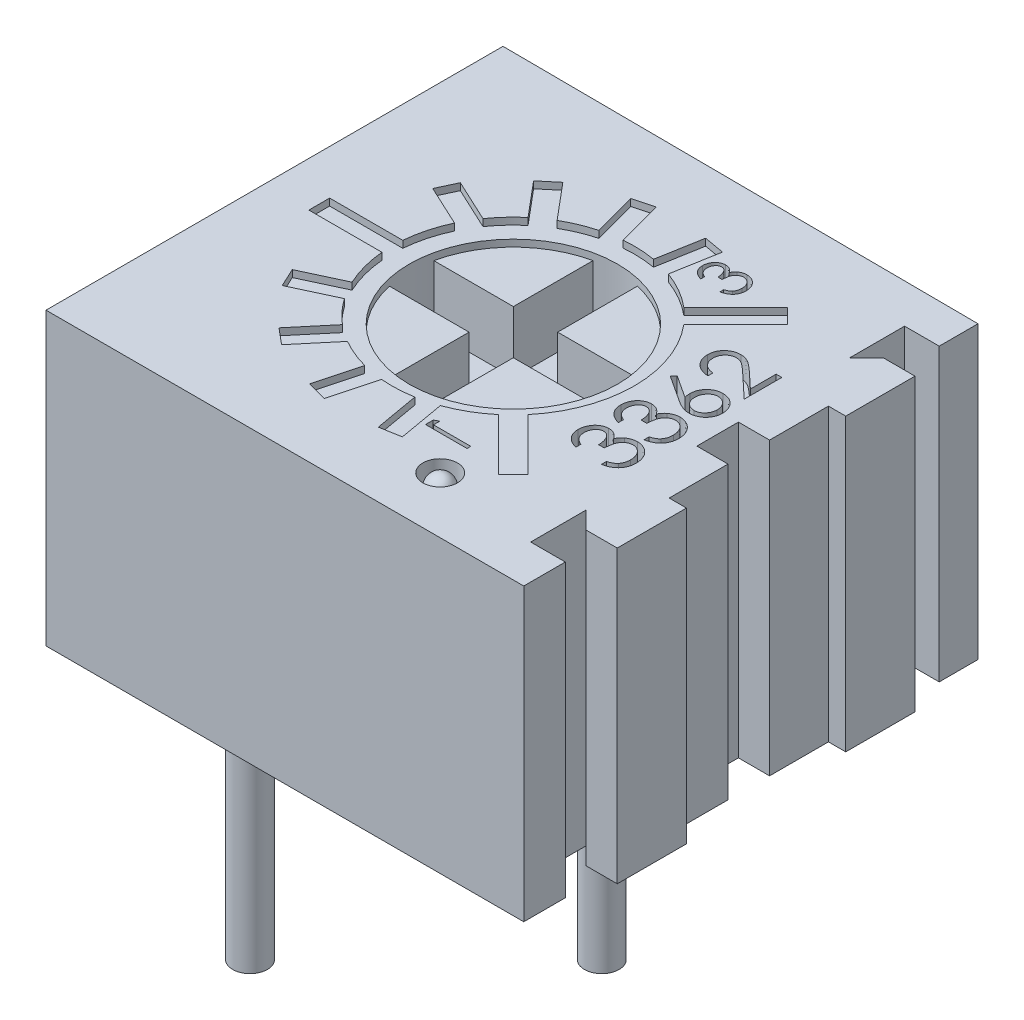
from build123d import *

# Parameters (mm, degrees)
BOSS_EXTRUDE1_DEPTH = 4.2
CUT_EXTRUDE3_DEPTH  = 0.2
CUT_EXTRUDE4_DEPTH  = 0.1
CUT_EXTRUDE5_DEPTH  = 0.5
CUT_EXTRUDE6_DEPTH  = 0.3
CUT_EXTRUDE7_DEPTH  = 0.89
SKETCH14_R          = 0.18
BOSS_EXTRUDE2_DEPTH = 0.32
REVOLVE1_ANGLE      = 180
BOSS_EXTRUDE3_DEPTH = 3.24


with BuildPart() as part:
    # Sketch3 → Boss-Extrude1 (new body)
    with BuildSketch(Plane(origin=(0, 0, 0), x_dir=(1, 0, 0), z_dir=(0, 1, 0))):
        Polygon((3.1, -1.938039121), (3.55, -1.938039121), (3.55, -0.938039121), (3.3, -0.938039121), (3.3, -0.088039121), (2.85, -0.088039121), (2.85, 0.511960879), (3.3, 0.511960879), (3.3, 1.361960879), (3.55, 1.361960879), (3.55, 2.361960879), (3.1, 2.361960879), (2.85, 2.111960879), (2.85, 2.911960879), (3.35, 2.911960879), (3.35, 3.472174064), (-3.55, 3.511960879), (-3.55, -3.088039121), (3.35, -3.088039121), (3.35, -2.488039121), (2.85, -2.488039121), (2.85, -1.688039121), align=None)
    extrude(amount=BOSS_EXTRUDE1_DEPTH)

    # Sketch5 → Cut-Extrude3 (cut)
    with BuildSketch(Plane(origin=(0, 4.2, 0), x_dir=(1, 0, 0), z_dir=(0, 1, 0))):
        with BuildLine():
            ThreePointArc((-1.60378018, 0.211962343), (-0.1, -1.291817837), (1.40378018, 0.211962343))
            ThreePointArc((1.40378018, 0.211962343), (-0.1, 1.715742524), (-1.60378018, 0.211962343))
        make_face()
    extrude(amount=-CUT_EXTRUDE3_DEPTH, mode=Mode.SUBTRACT)

    # Sketch5_5 → Cut-Extrude4 (cut)
    with BuildSketch(Plane(origin=(0, 4.2, 0), x_dir=(1, 0, 0), z_dir=(0, 1, 0))):
        with BuildLine():
            Line((-0.435140366, -2.183914718), (-0.260203012, -1.531039623))
            ThreePointArc((-0.260203012, -1.531039623), (-0.029388376, -1.536466305), (0.200131905, -1.511460589))
            Line((0.200131905, -1.511460589), (0.31300322, -2.151585629))
            Line((0.31300322, -2.151585629), (0.608445546, -2.099491175))
            Line((0.608445546, -2.099491175), (0.491075695, -1.433853672))
            ThreePointArc((0.491075695, -1.433853672), (0.770636357, -1.303944211), (1.023064377, -1.126995839))
            Line((1.023064377, -1.126995839), (1.770080564, -1.874012026))
            Line((1.770080564, -1.874012026), (1.982212598, -1.661879991))
            Line((1.982212598, -1.661879991), (1.235196412, -0.914863805))
            ThreePointArc((1.235196412, -0.914863805), (1.540276248, -0.387771779), (1.646247594, 0.211952979))
            ThreePointArc((1.646247594, 0.211952979), (1.540276248, 0.811677736), (1.235196412, 1.338769762))
            Line((1.235196412, 1.338769762), (1.982212598, 2.085785949))
            Line((1.982212598, 2.085785949), (1.770080564, 2.297917983))
            Line((1.770080564, 2.297917983), (1.023064377, 1.550901796))
            ThreePointArc((1.023064377, 1.550901796), (0.770636357, 1.727850169), (0.491075695, 1.857759629))
            Line((0.491075695, 1.857759629), (0.608445546, 2.523397133))
            Line((0.608445546, 2.523397133), (0.31300322, 2.575491586))
            Line((0.31300322, 2.575491586), (0.200131905, 1.935366546))
            ThreePointArc((0.200131905, 1.935366546), (-0.029388376, 1.960372262), (-0.260203012, 1.95494558))
            Line((-0.260203012, 1.95494558), (-0.435140366, 2.607820675))
            Line((-0.435140366, 2.607820675), (-0.724918114, 2.530174962))
            Line((-0.724918114, 2.530174962), (-0.556685735, 1.902323175))
            ThreePointArc((-0.556685735, 1.902323175), (-0.775269625, 1.827986588), (-0.982165312, 1.725521863))
            Line((-0.982165312, 1.725521863), (-1.416629336, 2.243295925))
            Line((-1.416629336, 2.243295925), (-1.646442669, 2.050459642))
            Line((-1.646442669, 2.050459642), (-1.228630723, 1.552530754))
            ThreePointArc((-1.228630723, 1.552530754), (-1.395319005, 1.392781383), (-1.539526714, 1.212478909))
            Line((-1.539526714, 1.212478909), (-2.152105616, 1.498129143))
            Line((-2.152105616, 1.498129143), (-2.278891095, 1.226236807))
            Line((-2.278891095, 1.226236807), (-1.689791033, 0.951534937))
            ThreePointArc((-1.689791033, 0.951534937), (-1.794449828, 0.663663314), (-1.847311983, 0.361952979))
            Line((-1.847311983, 0.361952979), (-2.903752406, 0.361952979))
            Line((-2.903752406, 0.361952979), (-2.903752406, 0.061952979))
            Line((-2.903752406, 0.061952979), (-1.847311983, 0.061952979))
            ThreePointArc((-1.847311983, 0.061952979), (-1.794449828, -0.239757357), (-1.689791033, -0.527628979))
            Line((-1.689791033, -0.527628979), (-2.278891095, -0.80233085))
            Line((-2.278891095, -0.80233085), (-2.152105616, -1.074223186))
            Line((-2.152105616, -1.074223186), (-1.539526714, -0.788572952))
            ThreePointArc((-1.539526714, -0.788572952), (-1.395319005, -0.968875425), (-1.228630723, -1.128624797))
            Line((-1.228630723, -1.128624797), (-1.646442669, -1.626553685))
            Line((-1.646442669, -1.626553685), (-1.416629336, -1.819389968))
            Line((-1.416629336, -1.819389968), (-0.982165312, -1.301615906))
            ThreePointArc((-0.982165312, -1.301615906), (-0.775269625, -1.40408063), (-0.556685735, -1.478417217))
            Line((-0.556685735, -1.478417217), (-0.724918114, -2.106269004))
            Line((-0.724918114, -2.106269004), (-0.435140366, -2.183914718))
        make_face()
    extrude(amount=-CUT_EXTRUDE4_DEPTH, mode=Mode.SUBTRACT)

    # Sketch5_6 → Cut-Extrude5 (cut)
    with BuildSketch(Plane(origin=(0, 4.2, 0), x_dir=(1, 0, 0), z_dir=(0, 1, 0))):
        with BuildLine():
            ThreePointArc((1.081757206, -2.276694537), (1.331757206, -2.526694537), (1.581757206, -2.276694537))
            ThreePointArc((1.581757206, -2.276694537), (1.331757206, -2.026694537), (1.081757206, -2.276694537))
        make_face()
    extrude(amount=-CUT_EXTRUDE5_DEPTH, mode=Mode.SUBTRACT)

    # Sketch10 → Cut-Extrude6 (cut)
    with BuildSketch(Plane(origin=(0, 4.2, 0), x_dir=(1, 0, 0), z_dir=(0, 1, 0))):
        Polygon((0.620519629, -1.666924235), (0.620519629, -1.777861735), (1.220519629, -1.777861735), (1.220519629, -1.724015581), (0.682058091, -1.724015581), (0.682058091, -1.631707889), align=None)
        with BuildLine():
            Line((0.78751456, 2.085640337), (0.78751456, 2.031794183))
            add(Edge.make_bspline(
                [(0.78751456, 2.031794183), (0.781474706, 2.033252963), (0.769667285, 2.036104759), (0.752797468, 2.042052915), (0.736833436, 2.048532787), (0.722074109, 2.056313776), (0.708222869, 2.064800991), (0.695593876, 2.074524886), (0.683865939, 2.085036839), (0.673457956, 2.096663973), (0.664033202, 2.108857458), (0.655997478, 2.121789107), (0.649084766, 2.135198746), (0.643389869, 2.149179283), (0.639099779, 2.163772341), (0.635987184, 2.178845991), (0.63396585, 2.194439734), (0.633768576, 2.205025035), (0.633668406, 2.210399953)],
                knots=[0, 0, 0, 0, 1.162005537, 2.271625781, 3.343758855, 4.383309926, 5.390229558, 6.379919256, 7.361854164, 8.333198761, 9.295911338, 10.242430842, 11.177959212, 12.116337295, 13.062827104, 14.020064771, 14.994644689, 16, 16, 16, 16], degree=3))
            add(Edge.make_bspline(
                [(0.633668406, 2.210399953), (0.633904846, 2.21823128), (0.634372567, 2.23372311), (0.638643614, 2.25648249), (0.645402208, 2.278429944), (0.654740561, 2.299325244), (0.666258386, 2.318734118), (0.679966627, 2.336003179), (0.695600793, 2.350898352), (0.712869232, 2.363394531), (0.731324462, 2.373178817), (0.750318775, 2.380393623), (0.769807113, 2.384785912), (0.782965504, 2.38535515), (0.78955783, 2.385640337)],
                knots=[0, 0, 0, 0, 1.083050992, 2.142477498, 3.193116406, 4.255571735, 5.30263384, 6.308962982, 7.297363603, 8.282367274, 9.249857812, 10.179914175, 11.08814088, 12, 12, 12, 12], degree=3))
            add(Edge.make_bspline(
                [(0.78955783, 2.385640337), (0.795901851, 2.385440864), (0.808316118, 2.385050527), (0.826439803, 2.381736178), (0.84352122, 2.376158533), (0.859632277, 2.368432288), (0.874670821, 2.358430879), (0.888670688, 2.346315559), (0.901693972, 2.332000817), (0.909154453, 2.321153), (0.91299533, 2.315568222)],
                knots=[0, 0, 0, 0, 1.024540389, 2.004866551, 2.965041327, 3.920577974, 4.882998113, 5.874504559, 6.905732034, 8, 8, 8, 8], degree=3))
            add(Edge.make_bspline(
                [(0.91299533, 2.315568222), (0.916066129, 2.321958944), (0.922160131, 2.334641333), (0.934301296, 2.351753576), (0.947975261, 2.367524746), (0.958765378, 2.376216651), (0.964197253, 2.38059226)],
                knots=[0, 0, 0, 0, 1.015663554, 2.015584519, 3.001021554, 4, 4, 4, 4], degree=3))
            add(Edge.make_bspline(
                [(0.964197253, 2.38059226), (0.96815001, 2.383479347), (0.975990796, 2.389206244), (0.98859704, 2.396275193), (1.00134301, 2.402688184), (1.014570336, 2.407685364), (1.02812571, 2.41155517), (1.042032407, 2.414321347), (1.056301782, 2.416039771), (1.06595535, 2.416285866), (1.07080783, 2.416409568)],
                knots=[0, 0, 0, 0, 1.025084078, 2.033381695, 3.024893161, 4.013698104, 4.991890475, 5.976764909, 6.982997093, 8, 8, 8, 8], degree=3))
            add(Edge.make_bspline(
                [(1.07080783, 2.416409568), (1.079209453, 2.416101893), (1.095973162, 2.41548799), (1.120740901, 2.410002242), (1.144948476, 2.401494523), (1.16811386, 2.389426201), (1.189767372, 2.374651777), (1.209284535, 2.357269018), (1.225797722, 2.337029416), (1.239762082, 2.314666489), (1.250820747, 2.290334097), (1.258791431, 2.264414964), (1.263572241, 2.237059086), (1.264145887, 2.218351768), (1.264437637, 2.208837453)],
                knots=[0, 0, 0, 0, 0.955697303, 1.906897079, 2.875188111, 3.870982192, 4.871999088, 5.854111427, 6.836107184, 7.836239895, 8.848948182, 9.870701427, 10.917064451, 12, 12, 12, 12], degree=3))
            add(Edge.make_bspline(
                [(1.264437637, 2.208837453), (1.264287502, 2.202423119), (1.263992087, 2.18980185), (1.26200853, 2.171240071), (1.25828723, 2.153559531), (1.253607181, 2.136588544), (1.247136489, 2.120583245), (1.239422225, 2.105313411), (1.230266568, 2.090845977), (1.219654119, 2.077266858), (1.20777507, 2.064590563), (1.194432076, 2.053140042), (1.179874164, 2.042788607), (1.163970382, 2.033602029), (1.146765276, 2.025541646), (1.128189901, 2.018780918), (1.108388261, 2.012877967), (1.094592692, 2.010128128), (1.08751456, 2.00871726)],
                knots=[0, 0, 0, 0, 1.048603596, 2.063302207, 3.045874044, 3.999447474, 4.937100059, 5.862643889, 6.7929026, 7.7308982, 8.676022965, 9.627908155, 10.600123445, 11.591992905, 12.626222643, 13.701663232, 14.820785756, 16, 16, 16, 16], degree=3))
            Line((1.08751456, 2.00871726), (1.08751456, 2.062563414))
            add(Edge.make_bspline(
                [(1.08751456, 2.062563414), (1.092134391, 2.063966264), (1.101120363, 2.066694929), (1.114052987, 2.071339666), (1.125908654, 2.07663137), (1.136774332, 2.082308151), (1.146757029, 2.08827017), (1.155592778, 2.0949413), (1.16366967, 2.10182744), (1.168220175, 2.107018186), (1.170447253, 2.109558606)],
                knots=[0, 0, 0, 0, 1.198163088, 2.33053128, 3.407730985, 4.417276592, 5.372219308, 6.28897303, 7.162600585, 8, 8, 8, 8], degree=3))
            add(Edge.make_bspline(
                [(1.170447253, 2.109558606), (1.173036185, 2.112918395), (1.178206058, 2.1196276), (1.184822365, 2.130553666), (1.190485766, 2.142084743), (1.195089216, 2.154316994), (1.198544731, 2.167252058), (1.201031848, 2.180837467), (1.202673732, 2.19509551), (1.202822932, 2.204826345), (1.202899176, 2.209798991)],
                knots=[0, 0, 0, 0, 0.946083416, 1.889246487, 2.84504177, 3.809995578, 4.801312957, 5.829064617, 6.89060985, 8, 8, 8, 8], degree=3))
            add(Edge.make_bspline(
                [(1.202899176, 2.209798991), (1.202793592, 2.215413877), (1.202587132, 2.226393302), (1.200688439, 2.242414135), (1.197923226, 2.257655412), (1.193652429, 2.271947914), (1.188375711, 2.285478858), (1.18175027, 2.298058569), (1.173976889, 2.309852187), (1.165141605, 2.320708657), (1.155469349, 2.330470744), (1.145352822, 2.339066089), (1.13483468, 2.346373174), (1.123856717, 2.352267501), (1.112464392, 2.356921882), (1.100625735, 2.36009043), (1.088437632, 2.362293547), (1.080152666, 2.362472966), (1.075976099, 2.362563414)],
                knots=[0, 0, 0, 0, 1.217147791, 2.380027433, 3.494444702, 4.572153297, 5.609568379, 6.639424714, 7.649109417, 8.668170816, 9.669597737, 10.625200337, 11.543417969, 12.441394052, 13.322311151, 14.205496177, 15.095365482, 16, 16, 16, 16], degree=3))
            add(Edge.make_bspline(
                [(1.075976099, 2.362563414), (1.070385941, 2.362300525), (1.059233442, 2.361776054), (1.042819359, 2.357788566), (1.026998802, 2.351170672), (1.011976674, 2.342087487), (0.99822378, 2.330760067), (0.985865181, 2.317723959), (0.975677157, 2.302624514), (0.968631668, 2.288737625), (0.963825561, 2.276434704), (0.96062408, 2.265906429), (0.957913186, 2.254119559), (0.955391077, 2.241216764), (0.953244561, 2.227100781), (0.951454535, 2.211786993), (0.950022243, 2.195272291), (0.949382626, 2.183839519), (0.949053022, 2.177948029)],
                knots=[0, 0, 0, 0, 1.070505987, 2.135685285, 3.216438728, 4.346150463, 5.486482244, 6.621737109, 7.7759408, 8.963942283, 9.59839197, 10.305095457, 11.070459627, 11.915156775, 12.823989992, 13.805807174, 14.869297358, 16, 16, 16, 16], degree=3))
            Line((0.949053022, 2.177948029), (0.88751456, 2.177948029))
            add(Edge.make_bspline(
                [(0.88751456, 2.177948029), (0.887370437, 2.185368404), (0.887088235, 2.199898012), (0.884359964, 2.221178252), (0.879980016, 2.241440875), (0.873721827, 2.260394602), (0.866350435, 2.277636886), (0.857832996, 2.292656041), (0.848192631, 2.30505668), (0.837613915, 2.314968358), (0.826329779, 2.322501929), (0.814496731, 2.327919856), (0.802067862, 2.331148945), (0.793582549, 2.331578346), (0.789317445, 2.331794183)],
                knots=[0, 0, 0, 0, 1.322091412, 2.58874672, 3.817242262, 5.011895168, 6.140903042, 7.155122731, 8.080855046, 8.929742606, 9.727943956, 10.488587771, 11.240295418, 12, 12, 12, 12], degree=3))
            add(Edge.make_bspline(
                [(0.789317445, 2.331794183), (0.786183596, 2.331724696), (0.779948952, 2.331586455), (0.770811699, 2.329773762), (0.761954172, 2.327175074), (0.753477364, 2.323402093), (0.745363924, 2.318513611), (0.737524849, 2.312617142), (0.73006143, 2.305544634), (0.722935163, 2.297623348), (0.716452233, 2.2888519), (0.710778596, 2.279434897), (0.705965601, 2.269410526), (0.701983565, 2.258842998), (0.698991443, 2.247683069), (0.69684219, 2.235987282), (0.695498662, 2.223732196), (0.695305209, 2.215371336), (0.695206868, 2.211121106)],
                knots=[0, 0, 0, 0, 0.884325644, 1.759323928, 2.622595547, 3.489424008, 4.37295195, 5.294616785, 6.255907374, 7.274251867, 8.302369084, 9.333474657, 10.37669385, 11.44084034, 12.520297356, 13.637342342, 14.798947025, 16, 16, 16, 16], degree=3))
            add(Edge.make_bspline(
                [(0.695206868, 2.211121106), (0.695445387, 2.204289392), (0.695911271, 2.190945464), (0.699991787, 2.171708622), (0.706502316, 2.153825307), (0.714273691, 2.140155821), (0.721945194, 2.130061666), (0.728645031, 2.122848477), (0.736090658, 2.11576496), (0.744740665, 2.10927713), (0.754009258, 2.102715877), (0.764367603, 2.096742524), (0.775545499, 2.090938005), (0.783447608, 2.087440425), (0.78751456, 2.085640337)],
                knots=[0, 0, 0, 0, 1.472543308, 2.876219568, 4.221790263, 5.565193594, 6.249813518, 6.953379497, 7.687249741, 8.463570142, 9.283606569, 10.136032583, 11.040678096, 12, 12, 12, 12], degree=3))
        make_face()
        with BuildLine():
            Line((2.0510798, 0.942912174), (2.0510798, 0.871117302))
            add(Edge.make_bspline(
                [(2.0510798, 0.871117302), (2.041555026, 0.871585223), (2.022848622, 0.872504207), (1.995574587, 0.876807816), (1.969504918, 0.88296573), (1.944848938, 0.891672348), (1.921388639, 0.902485212), (1.899217207, 0.915452075), (1.878419221, 0.93081067), (1.859187485, 0.948229352), (1.841544612, 0.967147898), (1.826309128, 0.987560684), (1.813436517, 1.009010976), (1.802675091, 1.031433696), (1.794597412, 1.055081824), (1.788603894, 1.079740763), (1.784997872, 1.105518852), (1.784610264, 1.123082285), (1.784413133, 1.132014738)],
                knots=[0, 0, 0, 0, 1.10065271, 2.161652631, 3.183658789, 4.190468796, 5.17591951, 6.163126047, 7.15150782, 8.156236427, 9.156009102, 10.134482811, 11.092018607, 12.041330605, 13.001268258, 13.972401359, 14.968799086, 16, 16, 16, 16], degree=3))
            add(Edge.make_bspline(
                [(1.784413133, 1.132014738), (1.784616828, 1.140787487), (1.785017082, 1.158025624), (1.788506035, 1.183173923), (1.793852546, 1.207171431), (1.801775232, 1.229746186), (1.811716471, 1.251129866), (1.824079703, 1.271057708), (1.838279943, 1.290011587), (1.855029822, 1.30706128), (1.872901985, 1.322723479), (1.891989305, 1.336223348), (1.911726182, 1.347849541), (1.932266789, 1.357365218), (1.953678017, 1.364578523), (1.975754589, 1.369922891), (1.998751282, 1.372978021), (2.014318943, 1.37344433), (2.022233646, 1.373681405)],
                knots=[0, 0, 0, 0, 1.111674182, 2.184400057, 3.212814286, 4.223731311, 5.211378316, 6.196328225, 7.191884489, 8.207283132, 9.220262353, 10.201199469, 11.166417575, 12.120932471, 13.06540007, 14.026332106, 14.996573967, 16, 16, 16, 16], degree=3))
            add(Edge.make_bspline(
                [(2.022233646, 1.373681405), (2.033376004, 1.373294367), (2.055465186, 1.372527084), (2.087925796, 1.365963887), (2.119375453, 1.355712916), (2.144687699, 1.343371757), (2.165081995, 1.330918465), (2.181881942, 1.319707464), (2.199966207, 1.306508495), (2.219407987, 1.291434323), (2.239952676, 1.274225349), (2.26201944, 1.25532866), (2.285200249, 1.234256244), (2.301043369, 1.219479413), (2.309252877, 1.21182243)],
                knots=[0, 0, 0, 0, 1.184416499, 2.348048165, 3.509039915, 4.696071444, 5.333504901, 6.05069495, 6.844171097, 7.714965912, 8.667477798, 9.695072654, 10.805644396, 12, 12, 12, 12], degree=3))
            Line((2.309252877, 1.21182243), (2.522874672, 1.011662174))
            Line((2.522874672, 1.011662174), (2.522874672, 1.383937815))
            Line((2.522874672, 1.383937815), (2.604925954, 1.383937815))
            Line((2.604925954, 1.383937815), (2.604925954, 0.840348071))
            Line((2.604925954, 0.840348071), (2.27383621, 1.150604482))
            add(Edge.make_bspline(
                [(2.27383621, 1.150604482), (2.265950883, 1.158158284), (2.250804783, 1.172667593), (2.228692107, 1.193189325), (2.208177926, 1.211621094), (2.189301001, 1.228082212), (2.171785214, 1.242215585), (2.156197853, 1.254757809), (2.141853978, 1.264807087), (2.125227552, 1.275713463), (2.104927594, 1.286276659), (2.080119894, 1.295353769), (2.054582236, 1.300888592), (2.037324628, 1.301552554), (2.028643903, 1.301886533)],
                knots=[0, 0, 0, 0, 1.329631726, 2.553950428, 3.673215718, 4.687767853, 5.603093632, 6.413772471, 7.123043292, 7.734684054, 8.834405432, 9.900288307, 10.943827018, 12, 12, 12, 12], degree=3))
            add(Edge.make_bspline(
                [(2.028643903, 1.301886533), (2.023185297, 1.30174122), (2.012427434, 1.301454837), (1.996654689, 1.298927364), (1.981439875, 1.295107819), (1.96673619, 1.289634617), (1.95269147, 1.28241022), (1.939288617, 1.273616304), (1.92633114, 1.263470004), (1.914181814, 1.251732571), (1.903054682, 1.238838509), (1.893197748, 1.225216967), (1.884960237, 1.210805514), (1.878207437, 1.195664915), (1.872910207, 1.179837379), (1.869239675, 1.163292294), (1.866935107, 1.146075376), (1.866623297, 1.134319149), (1.866464415, 1.128328841)],
                knots=[0, 0, 0, 0, 0.991446411, 1.95395049, 2.89581595, 3.838931463, 4.798493298, 5.75982156, 6.748411868, 7.785213223, 8.824556874, 9.840280684, 10.836137867, 11.835679398, 12.848801643, 13.863922112, 14.911575587, 16, 16, 16, 16], degree=3))
            add(Edge.make_bspline(
                [(1.866464415, 1.128328841), (1.866621402, 1.12207108), (1.866929699, 1.109781871), (1.869264891, 1.091776891), (1.872805044, 1.074482322), (1.878427578, 1.058156214), (1.885070882, 1.042445037), (1.893510484, 1.027684199), (1.903317489, 1.013628626), (1.914689111, 1.000509503), (1.927465951, 0.988527568), (1.94154691, 0.977851838), (1.956830617, 0.968585305), (1.973254345, 0.960489049), (1.990981612, 0.953917083), (2.009945464, 0.948894432), (2.030064691, 0.944920356), (2.043958417, 0.943592686), (2.0510798, 0.942912174)],
                knots=[0, 0, 0, 0, 1.030878251, 2.024474673, 2.987898669, 3.934362936, 4.864849709, 5.795128259, 6.730474222, 7.685293701, 8.650606017, 9.611896181, 10.591709709, 11.591680886, 12.625074257, 13.701333388, 14.821793024, 16, 16, 16, 16], degree=3))
        make_face()
        with BuildLine():
            Line((1.784413133, 0.594194225), (1.827842621, 0.649482687))
            Line((1.827842621, 0.649482687), (2.1510798, 0.438104482))
            add(Edge.make_bspline(
                [(2.1510798, 0.438104482), (2.148836632, 0.452177688), (2.144461079, 0.479629068), (2.143739263, 0.507415559), (2.143387492, 0.520957046)],
                knots=[0, 0, 0, 0, 1.025318673, 2, 2, 2, 2], degree=3))
            add(Edge.make_bspline(
                [(2.143387492, 0.520957046), (2.143606032, 0.529087902), (2.144036221, 0.545093251), (2.147346816, 0.568591948), (2.152563984, 0.591172277), (2.160169072, 0.612740643), (2.169883891, 0.633374479), (2.181527081, 0.653192124), (2.195699731, 0.671821328), (2.211532017, 0.689500931), (2.229066227, 0.70555532), (2.247676228, 0.719758016), (2.267360549, 0.731753379), (2.288114762, 0.741310151), (2.309776407, 0.748947705), (2.332429966, 0.754384713), (2.356113673, 0.757635039), (2.37222345, 0.758073874), (2.380406723, 0.758296789)],
                knots=[0, 0, 0, 0, 1.043709831, 2.054511743, 3.041122595, 4.01515914, 4.98481438, 5.965901842, 6.960491961, 7.985277438, 9.0096037, 10.00832444, 10.987059228, 11.962929573, 12.936966118, 13.931840027, 14.949438142, 16, 16, 16, 16], degree=3))
            add(Edge.make_bspline(
                [(2.380406723, 0.758296789), (2.391602503, 0.757972299), (2.413633148, 0.757333778), (2.445713267, 0.750944475), (2.476257117, 0.741090232), (2.504736177, 0.726779725), (2.531347695, 0.709341371), (2.554849568, 0.68781427), (2.575809493, 0.663266477), (2.59332912, 0.635495082), (2.6076389, 0.605611786), (2.617916534, 0.574216829), (2.62424422, 0.541616394), (2.625037496, 0.519489619), (2.625438774, 0.508296789)],
                knots=[0, 0, 0, 0, 1.031403119, 2.029557249, 3.004870281, 3.983165322, 4.960181699, 5.929903783, 6.912123683, 7.928973898, 8.949315281, 9.960468141, 10.968302741, 12, 12, 12, 12], degree=3))
            add(Edge.make_bspline(
                [(2.625438774, 0.508296789), (2.625090463, 0.497531376), (2.624400519, 0.476206977), (2.618222358, 0.444846108), (2.608279836, 0.414658773), (2.594295017, 0.386032469), (2.576928799, 0.359470509), (2.556167896, 0.335516962), (2.531983467, 0.314813802), (2.50490456, 0.297429378), (2.475846967, 0.283582688), (2.445495929, 0.273295876), (2.413978866, 0.267255419), (2.392611353, 0.266413269), (2.381849031, 0.265989097)],
                knots=[0, 0, 0, 0, 1.012172929, 2.004937354, 2.995255351, 3.995689452, 4.993936421, 5.973737378, 6.968231049, 7.979117505, 8.993136101, 9.989812463, 10.987515067, 12, 12, 12, 12], degree=3))
            add(Edge.make_bspline(
                [(2.381849031, 0.265989097), (2.373610269, 0.266259142), (2.356788291, 0.266810521), (2.331310799, 0.270660439), (2.305241981, 0.276846678), (2.283126736, 0.283774734), (2.265009817, 0.291094873), (2.250403305, 0.297186882), (2.235372202, 0.30476951), (2.219401086, 0.312854854), (2.202901558, 0.32217071), (2.185597862, 0.332300001), (2.167765193, 0.343522779), (2.155663663, 0.351390244), (2.149477236, 0.355412174)],
                knots=[0, 0, 0, 0, 1.173818275, 2.396712641, 3.66331629, 4.989737886, 5.693666774, 6.447286557, 7.243889047, 8.091586357, 8.998013824, 9.943181721, 10.948533338, 12, 12, 12, 12], degree=3))
            Line((2.149477236, 0.355412174), (1.784413133, 0.594194225))
        make_face()
        with BuildLine():
            add(Edge.make_bspline(
                [(2.225438774, 0.505892943), (2.225614896, 0.499798122), (2.225958913, 0.487893166), (2.228000129, 0.470436919), (2.231715374, 0.453862118), (2.236866886, 0.438163952), (2.243218096, 0.423245579), (2.251367258, 0.409402641), (2.260859171, 0.396350281), (2.271676664, 0.384297042), (2.283512378, 0.37336619), (2.29619153, 0.363953527), (2.3094061, 0.355834078), (2.323267143, 0.349232531), (2.337769193, 0.344091939), (2.352845594, 0.340373483), (2.368597435, 0.338304054), (2.37927915, 0.337959772), (2.384733646, 0.337783969)],
                knots=[0, 0, 0, 0, 1.129656352, 2.206547016, 3.251334079, 4.271920891, 5.265058649, 6.249872215, 7.241923875, 8.251504132, 9.246416584, 10.222533834, 11.173322129, 12.116503788, 13.062124155, 14.020151864, 14.989013135, 16, 16, 16, 16], degree=3))
            add(Edge.make_bspline(
                [(2.384733646, 0.337783969), (2.390138411, 0.337932207), (2.400789164, 0.338224329), (2.416423382, 0.34071145), (2.431434163, 0.344686855), (2.445765093, 0.350429595), (2.45969129, 0.357408168), (2.472778028, 0.366365704), (2.485449215, 0.376646353), (2.497116104, 0.388649949), (2.507947169, 0.401630588), (2.517453451, 0.415469791), (2.525491998, 0.429959184), (2.532152822, 0.445057037), (2.537056139, 0.46094998), (2.540809895, 0.47737995), (2.542862124, 0.494570332), (2.543210071, 0.506208526), (2.543387492, 0.512142943)],
                knots=[0, 0, 0, 0, 0.989367052, 1.949669134, 2.891858276, 3.827522767, 4.772653562, 5.738670152, 6.725809442, 7.756636004, 8.798867547, 9.819240912, 10.826537776, 11.829883227, 12.835515726, 13.868058748, 14.912904531, 16, 16, 16, 16], degree=3))
            add(Edge.make_bspline(
                [(2.543387492, 0.512142943), (2.543210057, 0.51807735), (2.542862083, 0.529715526), (2.54081005, 0.546906046), (2.537055569, 0.563335505), (2.532154887, 0.579230304), (2.525484292, 0.594321273), (2.517503756, 0.608798), (2.507888882, 0.622506314), (2.497134701, 0.635495401), (2.485382548, 0.647449112), (2.472892202, 0.657971551), (2.459586576, 0.666649234), (2.445819851, 0.673904502), (2.431425603, 0.679583656), (2.416425718, 0.683578632), (2.400788555, 0.686060463), (2.390138206, 0.686353311), (2.384733646, 0.686501917)],
                knots=[0, 0, 0, 0, 1.087281468, 2.132306021, 3.165025708, 4.170830268, 5.174347389, 6.181816599, 7.194310624, 8.23672049, 9.267723423, 10.261267456, 11.222032883, 12.171822355, 13.107646935, 14.049997283, 15.01046367, 16, 16, 16, 16], degree=3))
            add(Edge.make_bspline(
                [(2.384733646, 0.686501917), (2.379272035, 0.686376136), (2.368552667, 0.686129269), (2.352852641, 0.683337052), (2.337692591, 0.67946451), (2.32316781, 0.673616957), (2.309335571, 0.666020043), (2.296126168, 0.656766651), (2.283437674, 0.646062227), (2.271653503, 0.633696439), (2.260870898, 0.62023823), (2.251380312, 0.605917246), (2.243279109, 0.590994622), (2.236886618, 0.57526015), (2.231736754, 0.558925537), (2.228013375, 0.541877989), (2.225964234, 0.524105383), (2.225616158, 0.512041081), (2.225438774, 0.505892943)],
                knots=[0, 0, 0, 0, 0.978259475, 1.920005202, 2.851759169, 3.7803069, 4.719124913, 5.675758531, 6.668034766, 7.691045932, 8.733780038, 9.756656648, 10.768121246, 11.773215211, 12.79725739, 13.836288844, 14.897342417, 16, 16, 16, 16], degree=3))
        make_face(mode=Mode.SUBTRACT)
        with BuildLine():
            Line((1.989541339, -0.287857057), (1.989541339, -0.359651929))
            add(Edge.make_bspline(
                [(1.989541339, -0.359651929), (1.981488199, -0.357706889), (1.965744971, -0.353904494), (1.943251883, -0.34597362), (1.921966506, -0.33733379), (1.902287404, -0.326959138), (1.883819083, -0.315642851), (1.866980426, -0.302677658), (1.851343177, -0.288661721), (1.837465865, -0.273158876), (1.824899527, -0.256900896), (1.814185229, -0.239658697), (1.804968279, -0.221779178), (1.797375083, -0.203138462), (1.791654964, -0.183681052), (1.787504837, -0.163582852), (1.784809725, -0.142791195), (1.784546693, -0.12867746), (1.784413133, -0.121510903)],
                knots=[0, 0, 0, 0, 1.162005537, 2.271625781, 3.343758855, 4.383309926, 5.390229558, 6.379919256, 7.361854164, 8.333198761, 9.295911338, 10.242430842, 11.177959212, 12.116337295, 13.062827104, 14.020064771, 14.994644689, 16, 16, 16, 16], degree=3))
            add(Edge.make_bspline(
                [(1.784413133, -0.121510903), (1.784728386, -0.111069133), (1.785352015, -0.090413359), (1.791046743, -0.06006752), (1.800058202, -0.030804247), (1.812509339, -0.002943848), (1.82786644, 0.022934651), (1.846144094, 0.045960065), (1.866989648, 0.065820296), (1.890014235, 0.082481868), (1.914621208, 0.095527582), (1.939946958, 0.105147325), (1.965931409, 0.111003709), (1.98347593, 0.111762694), (1.992265697, 0.112142943)],
                knots=[0, 0, 0, 0, 1.083050992, 2.142477498, 3.193116406, 4.255571735, 5.30263384, 6.308962982, 7.297363603, 8.282367274, 9.249857812, 10.179914175, 11.08814088, 12, 12, 12, 12], degree=3))
            add(Edge.make_bspline(
                [(1.992265697, 0.112142943), (2.000724393, 0.111876979), (2.017276749, 0.11135653), (2.041441662, 0.106937397), (2.064216885, 0.099500537), (2.085698294, 0.089198877), (2.105749686, 0.075863666), (2.124416175, 0.059709906), (2.141780554, 0.040623584), (2.151727862, 0.026159826), (2.156849031, 0.018713456)],
                knots=[0, 0, 0, 0, 1.024540389, 2.004866551, 2.965041327, 3.920577974, 4.882998113, 5.874504559, 6.905732034, 8, 8, 8, 8], degree=3))
            add(Edge.make_bspline(
                [(2.156849031, 0.018713456), (2.16094343, 0.027234419), (2.169068767, 0.04414427), (2.185256986, 0.066960596), (2.203488939, 0.087988821), (2.217875763, 0.099578028), (2.225118262, 0.105412174)],
                knots=[0, 0, 0, 0, 1.015663554, 2.015584519, 3.001021554, 4, 4, 4, 4], degree=3))
            add(Edge.make_bspline(
                [(2.225118262, 0.105412174), (2.230388605, 0.109261624), (2.240842986, 0.116897486), (2.257651312, 0.12632275), (2.274645938, 0.134873405), (2.292282373, 0.141536312), (2.310356205, 0.146696053), (2.328898467, 0.150384289), (2.347924301, 0.152675521), (2.360795725, 0.153003648), (2.367265697, 0.153168584)],
                knots=[0, 0, 0, 0, 1.025084078, 2.033381695, 3.024893161, 4.013698104, 4.991890475, 5.976764909, 6.982997093, 8, 8, 8, 8], degree=3))
            add(Edge.make_bspline(
                [(2.367265697, 0.153168584), (2.378467862, 0.152758351), (2.400819474, 0.151939814), (2.433843127, 0.144625484), (2.466119892, 0.133281857), (2.497007072, 0.117190762), (2.525878421, 0.09749153), (2.551901305, 0.074314518), (2.573918888, 0.047328381), (2.592538034, 0.017511145), (2.607282921, -0.014932044), (2.6179105, -0.049490888), (2.624284912, -0.085965392), (2.625049775, -0.110908482), (2.625438774, -0.123594236)],
                knots=[0, 0, 0, 0, 0.955697303, 1.906897079, 2.875188111, 3.870982192, 4.871999088, 5.854111427, 6.836107184, 7.836239895, 8.848948182, 9.870701427, 10.917064451, 12, 12, 12, 12], degree=3))
            add(Edge.make_bspline(
                [(2.625438774, -0.123594236), (2.625238595, -0.132146681), (2.624844708, -0.14897504), (2.622199964, -0.173724078), (2.617238232, -0.197298132), (2.610998166, -0.219926114), (2.602370577, -0.241266513), (2.592084892, -0.261626291), (2.579877348, -0.280916204), (2.565727417, -0.299021696), (2.549888685, -0.315923422), (2.532098026, -0.331190784), (2.512687477, -0.344992698), (2.491482435, -0.357241468), (2.468542293, -0.367988645), (2.443775126, -0.377002949), (2.417372939, -0.38487355), (2.398978848, -0.388540002), (2.389541339, -0.390421159)],
                knots=[0, 0, 0, 0, 1.048603596, 2.063302207, 3.045874044, 3.999447474, 4.937100059, 5.862643889, 6.7929026, 7.7308982, 8.676022965, 9.627908155, 10.600123445, 11.591992905, 12.626222643, 13.701663232, 14.820785756, 16, 16, 16, 16], degree=3))
            Line((2.389541339, -0.390421159), (2.389541339, -0.318626288))
            add(Edge.make_bspline(
                [(2.389541339, -0.318626288), (2.395701113, -0.316755821), (2.407682409, -0.313117601), (2.424925908, -0.306924619), (2.440733463, -0.299869014), (2.455221034, -0.292299972), (2.468531297, -0.284350612), (2.480312296, -0.275455772), (2.491081485, -0.266274254), (2.497148825, -0.259353259), (2.500118262, -0.255966031)],
                knots=[0, 0, 0, 0, 1.198163088, 2.33053128, 3.407730985, 4.417276592, 5.372219308, 6.28897303, 7.162600585, 8, 8, 8, 8], degree=3))
            add(Edge.make_bspline(
                [(2.500118262, -0.255966031), (2.503570171, -0.251486313), (2.510463335, -0.242540706), (2.519285078, -0.227972619), (2.526836279, -0.212597849), (2.532974212, -0.196288181), (2.537581566, -0.179041429), (2.540897722, -0.160927551), (2.543086901, -0.141916827), (2.543285834, -0.12894238), (2.543387492, -0.122312185)],
                knots=[0, 0, 0, 0, 0.946083416, 1.889246487, 2.84504177, 3.809995578, 4.801312957, 5.829064617, 6.89060985, 8, 8, 8, 8], degree=3))
            add(Edge.make_bspline(
                [(2.543387492, -0.122312185), (2.543246714, -0.11482567), (2.542971434, -0.100186437), (2.540439844, -0.078825326), (2.536752892, -0.058503624), (2.531058496, -0.039446955), (2.524022873, -0.021405696), (2.515188952, -0.004632748), (2.504824444, 0.011092077), (2.493044065, 0.025567369), (2.480147723, 0.038583485), (2.466659021, 0.050043946), (2.452634832, 0.059786725), (2.437997547, 0.067645829), (2.42280778, 0.073851669), (2.407022905, 0.078076401), (2.390772101, 0.08101389), (2.37972548, 0.081253115), (2.374156723, 0.081373712)],
                knots=[0, 0, 0, 0, 1.217147791, 2.380027433, 3.494444702, 4.572153297, 5.609568379, 6.639424714, 7.649109417, 8.668170816, 9.669597737, 10.625200337, 11.543417969, 12.441394052, 13.322311151, 14.205496177, 15.095365482, 16, 16, 16, 16], degree=3))
            add(Edge.make_bspline(
                [(2.374156723, 0.081373712), (2.36670318, 0.081023193), (2.35183318, 0.080323899), (2.329947737, 0.075007248), (2.308853661, 0.066183389), (2.288824157, 0.054072476), (2.270486965, 0.038969249), (2.254008833, 0.021587772), (2.240424801, 0.001455179), (2.231030816, -0.017060673), (2.224622673, -0.033464568), (2.220354032, -0.047502268), (2.216739506, -0.063218094), (2.213376693, -0.080421822), (2.210514673, -0.099243131), (2.208127972, -0.119661516), (2.206218248, -0.141681119), (2.205365427, -0.156924814), (2.204925954, -0.164780134)],
                knots=[0, 0, 0, 0, 1.070505987, 2.135685285, 3.216438728, 4.346150463, 5.486482244, 6.621737109, 7.7759408, 8.963942283, 9.59839197, 10.305095457, 11.070459627, 11.915156775, 12.823989992, 13.805807174, 14.869297358, 16, 16, 16, 16], degree=3))
            Line((2.204925954, -0.164780134), (2.122874672, -0.164780134))
            add(Edge.make_bspline(
                [(2.122874672, -0.164780134), (2.122682508, -0.154886301), (2.122306238, -0.13551349), (2.118668543, -0.107139838), (2.112828613, -0.080123006), (2.10448436, -0.05485137), (2.094655839, -0.031861658), (2.083299253, -0.011836119), (2.070445433, 0.004698067), (2.056340478, 0.017913637), (2.041294963, 0.027958399), (2.025517566, 0.035182301), (2.008945741, 0.039487753), (1.99763199, 0.040060289), (1.991945185, 0.040348071)],
                knots=[0, 0, 0, 0, 1.322091412, 2.58874672, 3.817242262, 5.011895168, 6.140903042, 7.155122731, 8.080855046, 8.929742606, 9.727943956, 10.488587771, 11.240295418, 12, 12, 12, 12], degree=3))
            add(Edge.make_bspline(
                [(1.991945185, 0.040348071), (1.987766719, 0.040255422), (1.97945386, 0.0400711), (1.967270856, 0.037654176), (1.955460821, 0.034189259), (1.94415841, 0.029158617), (1.93334049, 0.022640642), (1.92288839, 0.014778683), (1.912937165, 0.005348672), (1.903435476, -0.005213043), (1.894791569, -0.016908307), (1.88722672, -0.02946431), (1.880809392, -0.042830139), (1.875500011, -0.056920175), (1.871510515, -0.071800082), (1.868644844, -0.087394463), (1.866853474, -0.103734578), (1.866595537, -0.114882392), (1.866464415, -0.120549365)],
                knots=[0, 0, 0, 0, 0.884325644, 1.759323928, 2.622595547, 3.489424008, 4.37295195, 5.294616785, 6.255907374, 7.274251867, 8.302369084, 9.333474657, 10.37669385, 11.44084034, 12.520297356, 13.637342342, 14.798947025, 16, 16, 16, 16], degree=3))
            add(Edge.make_bspline(
                [(1.866464415, -0.120549365), (1.866782441, -0.129658317), (1.867403619, -0.14745022), (1.872844308, -0.173099344), (1.881525013, -0.196943764), (1.891886846, -0.215169744), (1.902115516, -0.228628619), (1.911048633, -0.238246204), (1.920976136, -0.247690893), (1.932509479, -0.256341333), (1.944867602, -0.26508967), (1.958678729, -0.273054142), (1.973582591, -0.2807935), (1.984118736, -0.28545694), (1.989541339, -0.287857057)],
                knots=[0, 0, 0, 0, 1.472543308, 2.876219568, 4.221790263, 5.565193594, 6.249813518, 6.953379497, 7.687249741, 8.463570142, 9.283606569, 10.136032583, 11.040678096, 12, 12, 12, 12], degree=3))
        make_face()
        with BuildLine():
            Line((1.989541339, -0.903241672), (1.989541339, -0.975036544))
            add(Edge.make_bspline(
                [(1.989541339, -0.975036544), (1.981488199, -0.973091504), (1.965744971, -0.96928911), (1.943251883, -0.961358236), (1.921966506, -0.952718406), (1.902287404, -0.942343753), (1.883819083, -0.931027467), (1.866980426, -0.918062273), (1.851343177, -0.904046337), (1.837465865, -0.888543491), (1.824899527, -0.872285511), (1.814185229, -0.855043312), (1.804968279, -0.837163794), (1.797375083, -0.818523078), (1.791654964, -0.799065667), (1.787504837, -0.778967467), (1.784809725, -0.75817581), (1.784546693, -0.744062075), (1.784413133, -0.736895518)],
                knots=[0, 0, 0, 0, 1.162005537, 2.271625781, 3.343758855, 4.383309926, 5.390229558, 6.379919256, 7.361854164, 8.333198761, 9.295911338, 10.242430842, 11.177959212, 12.116337295, 13.062827104, 14.020064771, 14.994644689, 16, 16, 16, 16], degree=3))
            add(Edge.make_bspline(
                [(1.784413133, -0.736895518), (1.784728386, -0.726453749), (1.785352015, -0.705797975), (1.791046743, -0.675452136), (1.800058202, -0.646188863), (1.812509339, -0.618328463), (1.82786644, -0.592449964), (1.846144094, -0.56942455), (1.866989648, -0.549564319), (1.890014235, -0.532902747), (1.914621208, -0.519857033), (1.939946958, -0.51023729), (1.965931409, -0.504380906), (1.98347593, -0.503621922), (1.992265697, -0.503241672)],
                knots=[0, 0, 0, 0, 1.083050992, 2.142477498, 3.193116406, 4.255571735, 5.30263384, 6.308962982, 7.297363603, 8.282367274, 9.249857812, 10.179914175, 11.08814088, 12, 12, 12, 12], degree=3))
            add(Edge.make_bspline(
                [(1.992265697, -0.503241672), (2.000724393, -0.503507636), (2.017276749, -0.504028086), (2.041441662, -0.508447218), (2.064216885, -0.515884078), (2.085698294, -0.526185738), (2.105749686, -0.53952095), (2.124416175, -0.555674709), (2.141780554, -0.574761032), (2.151727862, -0.589224789), (2.156849031, -0.596671159)],
                knots=[0, 0, 0, 0, 1.024540389, 2.004866551, 2.965041327, 3.920577974, 4.882998113, 5.874504559, 6.905732034, 8, 8, 8, 8], degree=3))
            add(Edge.make_bspline(
                [(2.156849031, -0.596671159), (2.16094343, -0.588150197), (2.169068767, -0.571240345), (2.185256986, -0.54842402), (2.203488939, -0.527395794), (2.217875763, -0.515806587), (2.225118262, -0.509972442)],
                knots=[0, 0, 0, 0, 1.015663554, 2.015584519, 3.001021554, 4, 4, 4, 4], degree=3))
            add(Edge.make_bspline(
                [(2.225118262, -0.509972442), (2.230388605, -0.506122992), (2.240842986, -0.49848713), (2.257651312, -0.489061865), (2.274645938, -0.48051121), (2.292282373, -0.473848303), (2.310356205, -0.468688562), (2.328898467, -0.465000326), (2.347924301, -0.462709094), (2.360795725, -0.462380968), (2.367265697, -0.462216031)],
                knots=[0, 0, 0, 0, 1.025084078, 2.033381695, 3.024893161, 4.013698104, 4.991890475, 5.976764909, 6.982997093, 8, 8, 8, 8], degree=3))
            add(Edge.make_bspline(
                [(2.367265697, -0.462216031), (2.378467862, -0.462626265), (2.400819474, -0.463444802), (2.433843127, -0.470759132), (2.466119892, -0.482102758), (2.497007072, -0.498193853), (2.525878421, -0.517893085), (2.551901305, -0.541070097), (2.573918888, -0.568056234), (2.592538034, -0.59787347), (2.607282921, -0.630316659), (2.6179105, -0.664875504), (2.624284912, -0.701350007), (2.625049775, -0.726293097), (2.625438774, -0.738978852)],
                knots=[0, 0, 0, 0, 0.955697303, 1.906897079, 2.875188111, 3.870982192, 4.871999088, 5.854111427, 6.836107184, 7.836239895, 8.848948182, 9.870701427, 10.917064451, 12, 12, 12, 12], degree=3))
            add(Edge.make_bspline(
                [(2.625438774, -0.738978852), (2.625238595, -0.747531296), (2.624844708, -0.764359655), (2.622199964, -0.789108694), (2.617238232, -0.812682747), (2.610998166, -0.835310729), (2.602370577, -0.856651128), (2.592084892, -0.877010906), (2.579877348, -0.89630082), (2.565727417, -0.914406311), (2.549888685, -0.931308038), (2.532098026, -0.946575399), (2.512687477, -0.960377313), (2.491482435, -0.972626083), (2.468542293, -0.98337326), (2.443775126, -0.992387564), (2.417372939, -1.000258165), (2.398978848, -1.003924618), (2.389541339, -1.005805775)],
                knots=[0, 0, 0, 0, 1.048603596, 2.063302207, 3.045874044, 3.999447474, 4.937100059, 5.862643889, 6.7929026, 7.7308982, 8.676022965, 9.627908155, 10.600123445, 11.591992905, 12.626222643, 13.701663232, 14.820785756, 16, 16, 16, 16], degree=3))
            Line((2.389541339, -1.005805775), (2.389541339, -0.934010903))
            add(Edge.make_bspline(
                [(2.389541339, -0.934010903), (2.395701113, -0.932140436), (2.407682409, -0.928502216), (2.424925908, -0.922309234), (2.440733463, -0.915253629), (2.455221034, -0.907684587), (2.468531297, -0.899735228), (2.480312296, -0.890840388), (2.491081485, -0.881658869), (2.497148825, -0.874737874), (2.500118262, -0.871350647)],
                knots=[0, 0, 0, 0, 1.198163088, 2.33053128, 3.407730985, 4.417276592, 5.372219308, 6.28897303, 7.162600585, 8, 8, 8, 8], degree=3))
            add(Edge.make_bspline(
                [(2.500118262, -0.871350647), (2.503570171, -0.866870929), (2.510463335, -0.857925321), (2.519285078, -0.843357234), (2.526836279, -0.827982464), (2.532974212, -0.811672797), (2.537581566, -0.794426044), (2.540897722, -0.776312166), (2.543086901, -0.757301442), (2.543285834, -0.744326995), (2.543387492, -0.7376968)],
                knots=[0, 0, 0, 0, 0.946083416, 1.889246487, 2.84504177, 3.809995578, 4.801312957, 5.829064617, 6.89060985, 8, 8, 8, 8], degree=3))
            add(Edge.make_bspline(
                [(2.543387492, -0.7376968), (2.543246714, -0.730210286), (2.542971434, -0.715571052), (2.540439844, -0.694209941), (2.536752892, -0.673888239), (2.531058496, -0.65483157), (2.524022873, -0.636790311), (2.515188952, -0.620017363), (2.504824444, -0.604292539), (2.493044065, -0.589817246), (2.480147723, -0.57680113), (2.466659021, -0.56534067), (2.452634832, -0.55559789), (2.437997547, -0.547738786), (2.42280778, -0.541532946), (2.407022905, -0.537308215), (2.390772101, -0.534370726), (2.37972548, -0.5341315), (2.374156723, -0.534010903)],
                knots=[0, 0, 0, 0, 1.217147791, 2.380027433, 3.494444702, 4.572153297, 5.609568379, 6.639424714, 7.649109417, 8.668170816, 9.669597737, 10.625200337, 11.543417969, 12.441394052, 13.322311151, 14.205496177, 15.095365482, 16, 16, 16, 16], degree=3))
            add(Edge.make_bspline(
                [(2.374156723, -0.534010903), (2.36670318, -0.534361422), (2.35183318, -0.535060717), (2.329947737, -0.540377367), (2.308853661, -0.549201226), (2.288824157, -0.561312139), (2.270486965, -0.576415366), (2.254008833, -0.593796843), (2.240424801, -0.613929436), (2.231030816, -0.632445288), (2.224622673, -0.648849183), (2.220354032, -0.662886884), (2.216739506, -0.67860271), (2.213376693, -0.695806437), (2.210514673, -0.714627747), (2.208127972, -0.735046132), (2.206218248, -0.757065734), (2.205365427, -0.772309429), (2.204925954, -0.780164749)],
                knots=[0, 0, 0, 0, 1.070505987, 2.135685285, 3.216438728, 4.346150463, 5.486482244, 6.621737109, 7.7759408, 8.963942283, 9.59839197, 10.305095457, 11.070459627, 11.915156775, 12.823989992, 13.805807174, 14.869297358, 16, 16, 16, 16], degree=3))
            Line((2.204925954, -0.780164749), (2.122874672, -0.780164749))
            add(Edge.make_bspline(
                [(2.122874672, -0.780164749), (2.122682508, -0.770270917), (2.122306238, -0.750898106), (2.118668543, -0.722524453), (2.112828613, -0.695507622), (2.10448436, -0.670235986), (2.094655839, -0.647246273), (2.083299253, -0.627220734), (2.070445433, -0.610686548), (2.056340478, -0.597470978), (2.041294963, -0.587426216), (2.025517566, -0.580202314), (2.008945741, -0.575896862), (1.99763199, -0.575324327), (1.991945185, -0.575036544)],
                knots=[0, 0, 0, 0, 1.322091412, 2.58874672, 3.817242262, 5.011895168, 6.140903042, 7.155122731, 8.080855046, 8.929742606, 9.727943956, 10.488587771, 11.240295418, 12, 12, 12, 12], degree=3))
            add(Edge.make_bspline(
                [(1.991945185, -0.575036544), (1.987766719, -0.575129194), (1.97945386, -0.575313515), (1.967270856, -0.577730439), (1.955460821, -0.581195356), (1.94415841, -0.586225998), (1.93334049, -0.592743973), (1.92288839, -0.600605932), (1.912937165, -0.610035944), (1.903435476, -0.620597658), (1.894791569, -0.632292922), (1.88722672, -0.644848925), (1.880809392, -0.658214754), (1.875500011, -0.672304791), (1.871510515, -0.687184697), (1.868644844, -0.702779079), (1.866853474, -0.719119193), (1.866595537, -0.730267008), (1.866464415, -0.73593398)],
                knots=[0, 0, 0, 0, 0.884325644, 1.759323928, 2.622595547, 3.489424008, 4.37295195, 5.294616785, 6.255907374, 7.274251867, 8.302369084, 9.333474657, 10.37669385, 11.44084034, 12.520297356, 13.637342342, 14.798947025, 16, 16, 16, 16], degree=3))
            add(Edge.make_bspline(
                [(1.866464415, -0.73593398), (1.866782441, -0.745042933), (1.867403619, -0.762834836), (1.872844308, -0.78848396), (1.881525013, -0.812328379), (1.891886846, -0.83055436), (1.902115516, -0.844013234), (1.911048633, -0.85363082), (1.920976136, -0.863075508), (1.932509479, -0.871725948), (1.944867602, -0.880474286), (1.958678729, -0.888438757), (1.973582591, -0.896178115), (1.984118736, -0.900841555), (1.989541339, -0.903241672)],
                knots=[0, 0, 0, 0, 1.472543308, 2.876219568, 4.221790263, 5.565193594, 6.249813518, 6.953379497, 7.687249741, 8.463570142, 9.283606569, 10.136032583, 11.040678096, 12, 12, 12, 12], degree=3))
        make_face()
    extrude(amount=-CUT_EXTRUDE6_DEPTH, mode=Mode.SUBTRACT)

    # Sketch11 → Cut-Extrude7 (cut)
    with BuildSketch(Plane(origin=(0, 4, 0), x_dir=(1, 0, 0), z_dir=(0, 1, 0))):
        with BuildLine():
            Line((-0.42, 0.531962343), (-0.42, 1.681300572))
            ThreePointArc((-0.42, 1.681300572), (-0.1, 1.715742524), (0.22, 1.681300572))
            Line((0.22, 1.681300572), (0.22, 0.531962343))
            Line((0.22, 0.531962343), (1.369338229, 0.531962343))
            ThreePointArc((1.369338229, 0.531962343), (1.40378018, 0.211962343), (1.369338229, -0.108037657))
            Line((1.369338229, -0.108037657), (0.22, -0.108037657))
            Line((0.22, -0.108037657), (0.22, -1.257375885))
            ThreePointArc((0.22, -1.257375885), (-0.1, -1.291817837), (-0.42, -1.257375885))
            Line((-0.42, -1.257375885), (-0.42, -0.108037657))
            Line((-0.42, -0.108037657), (-1.569338229, -0.108037657))
            ThreePointArc((-1.569338229, -0.108037657), (-1.60378018, 0.211962343), (-1.569338229, 0.531962343))
            Line((-1.569338229, 0.531962343), (-0.42, 0.531962343))
        make_face()
    extrude(amount=-CUT_EXTRUDE7_DEPTH, mode=Mode.SUBTRACT)



with BuildPart() as body_2:
    # Sketch14 → Boss-Extrude2 (new body)
    with BuildSketch(Plane(origin=(0, 3.7, 0), x_dir=(1, 0, 0), z_dir=(0, 1, 0))):
        with Locations(Location((1.331757206, -2.276694537, 0), (0, 0, 270))):
            Circle(SKETCH14_R)
    extrude(amount=BOSS_EXTRUDE2_DEPTH)


with BuildPart() as part_1:
    add(part.part)

    add(body_2.part)  # Revolve1 merges body 2
    # Sketch15 → Revolve1 (revolve)
    with BuildSketch(Plane(origin=(0, 4.02, 0), x_dir=(1, 0, 0), z_dir=(0, 1, 0))):
        with BuildLine():
            Line((1.222052953, -2.419400448), (1.441461458, -2.133988626))
            ThreePointArc((1.441461458, -2.133988626), (1.474463117, -2.38639879), (1.222052953, -2.419400448))
        make_face()
    revolve(axis=Axis((1.222052953, 4.02, 2.419400448), (-0.6094680694070695, 0, 0.7928106157041664)), revolution_arc=REVOLVE1_ANGLE)

    # Sketch17 → Boss-Extrude3 (add)
    with BuildSketch(Plane.XZ):
        with BuildLine():
            ThreePointArc((-1.644341327, -2.782983926), (-1.394341327, -3.032983926), (-1.144341327, -2.782983926))
            ThreePointArc((-1.144341327, -2.782983926), (-1.394341327, -2.532983926), (-1.644341327, -2.782983926))
        make_face()
        with BuildLine():
            ThreePointArc((0.895658673, -0.242983926), (1.145658673, -0.492983926), (1.395658673, -0.242983926))
            ThreePointArc((1.395658673, -0.242983926), (1.145658673, 0.007016074), (0.895658673, -0.242983926))
        make_face()
        with BuildLine():
            ThreePointArc((-1.644341327, 2.297016074), (-1.394341327, 2.047016074), (-1.144341327, 2.297016074))
            ThreePointArc((-1.144341327, 2.297016074), (-1.394341327, 2.547016074), (-1.644341327, 2.297016074))
        make_face()
    extrude(amount=BOSS_EXTRUDE3_DEPTH)


solid = part_1.part
